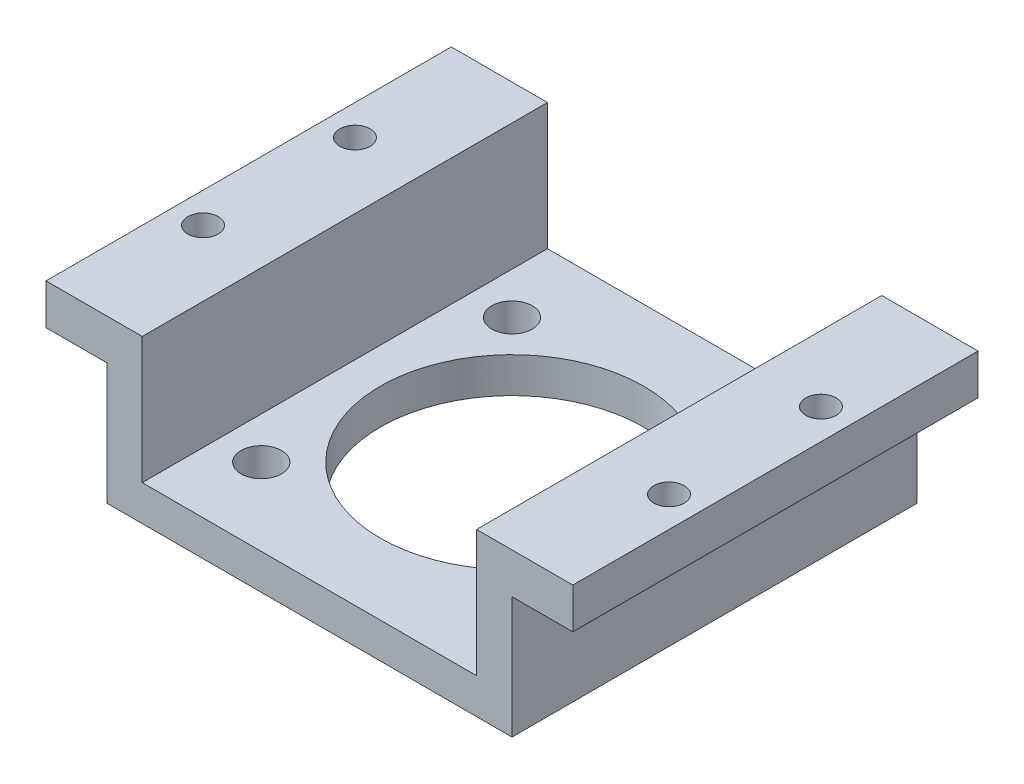
from build123d import *

# Parameters (mm, degrees)
EXTRUDE_1_DEPTH          = 40
SKETCH_2_R               = 13
CUT_EXTRUDE_1_DEPTH      = 1.5
SKETCH_3_R               = 13
CUT_EXTRUDE_2_DEPTH      = 15.5
SKETCH_4_R               = 2
CUT_EXTRUDE_3_DEPTH      = 5
PATTERN_CIRCULAR_1_COUNT = 4
SKETCH_5_R               = 1.5
CUT_EXTRUDE_4_DEPTH      = 7
SKETCH_6_W               = 33
SKETCH_6_H               = 40
CUT_EXTRUDE_5_DEPTH      = 1.5
SKETCH_7_W               = 6
SKETCH_7_H               = 40
CUT_EXTRUDE_6_DEPTH      = 2


with BuildPart() as part:
    # 草图1 → 凸台-拉伸1 (new body)
    with BuildSketch(Plane.XY):
        Polygon((-16.5, 27.398785639), (-16.5, 16.398785639), (16.5, 16.398785639), (16.5, 27.398785639), (26, 27.398785639), (26, 21.398785639), (20, 21.398785639), (20, 16.398785639), (20, 11.398785639), (-20, 11.398785639), (-20, 21.398785639), (-26, 21.398785639), (-26, 27.398785639), align=None)
    extrude(amount=EXTRUDE_1_DEPTH)

    # 草图2 → 切除-拉伸1 (cut)
    with BuildSketch(Plane.XZ.offset(-11.398785639)):
        with Locations((0, 20)):
            Circle(SKETCH_2_R)
    extrude(amount=-CUT_EXTRUDE_1_DEPTH, mode=Mode.SUBTRACT)

    # 草图3 → 切除-拉伸2 (cut, through all)
    with BuildSketch(Plane.XZ.offset(-12.898785639)):
        with Locations((0, 20)):
            Circle(SKETCH_3_R)
    extrude(amount=-CUT_EXTRUDE_2_DEPTH, mode=Mode.SUBTRACT)

    # 草图4 → 切除-拉伸3 (cut)
    with BuildSketch(Plane.XZ.offset(-11.398785639)):
        with Locations((12.374368671, 32.374368671)):
            Circle(SKETCH_4_R)
    cut_extrude_3 = extrude(amount=-CUT_EXTRUDE_3_DEPTH, mode=Mode.SUBTRACT)

    # 阵列(圆周)1: 切除-拉伸3 ×4 about axis
    pattern_circular_1_axis = Axis((0, 0, 20), (0, 1, 0))
    for i in range(1, PATTERN_CIRCULAR_1_COUNT):
        add(cut_extrude_3.rotate(pattern_circular_1_axis, i * 360 / PATTERN_CIRCULAR_1_COUNT), mode=Mode.SUBTRACT)

    # 草图5 → 切除-拉伸4 (cut, through all)
    with BuildSketch(Plane.XZ.offset(-21.398785639)):
        with Locations((-23, 27.5)):
            Circle(SKETCH_5_R)
        with Locations((-23, 12.5)):
            Circle(SKETCH_5_R)
    cut_extrude_4 = extrude(amount=-CUT_EXTRUDE_4_DEPTH, mode=Mode.SUBTRACT)

    # 镜向1: 切除-拉伸4 across plane
    add(cut_extrude_4.mirror(Plane.ZY), mode=Mode.SUBTRACT)

    # 草图6 → 切除-拉伸5 (cut)
    with BuildSketch(Plane(origin=(0, 16.398785639, 0), x_dir=(1, 0, 0), z_dir=(0, 1, 0))):
        with Locations((0, -20)):
            Rectangle(SKETCH_6_W, SKETCH_6_H)
    extrude(amount=-CUT_EXTRUDE_5_DEPTH, mode=Mode.SUBTRACT)

    # 草图7 → 切除-拉伸6 (cut)
    with BuildSketch(Plane.XZ.offset(-21.398785639)):
        with Locations((-23, 20)):
            Rectangle(SKETCH_7_W, SKETCH_7_H)
        with Locations((23, 20)):
            Rectangle(SKETCH_7_W, SKETCH_7_H)
    extrude(amount=-CUT_EXTRUDE_6_DEPTH, mode=Mode.SUBTRACT)


solid = part.part
